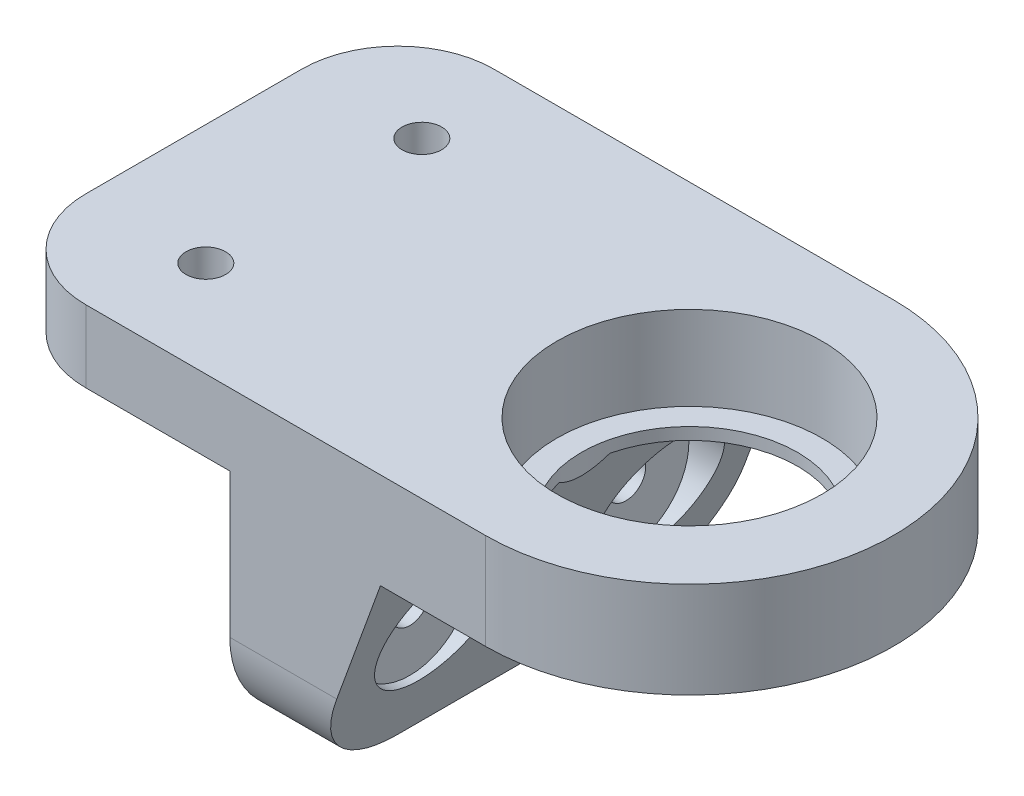
from build123d import *

# Parameters (mm, degrees)
RESSALTO_EXTRUS_O1_DEPTH   = 40
CORTE_EXTRUS_O1_DEPTH      = 66.76473219
CORTE_EXTRUS_O1_DEPTH_BACK = 66.76473219
ESBO_O2_R                  = 1.65
ESBO_O2_R_2                = 9
ESBO_O3_R                  = 1.65
CORTE_EXTRUS_O2_DEPTH      = 60.261201473
ESBO_O4_R                  = 11.05
CORTE_EXTRUS_O3_DEPTH      = 7
CORTE_EXTRUS_O5_START      = 7
ESBO_O7_R                  = 5.25
CORTE_EXTRUS_O5_DEPTH      = 10
FILETE1_R                  = 8
ESBO_O8_R                  = 5.25
CORTE_EXTRUS_O6_DEPTH      = 1
ESBO_O7_2_R                = 5.25
CORTE_EXTRUS_O7_DEPTH      = 1


with BuildPart() as part:
    # Esboço1 → Ressalto-extrusão1 (new body)
    with BuildSketch(Plane.XY):
        Polygon((0, 0), (6, 0), (12.551464217, 18), (49, 18), (49, 26), (-20, 26), (-20, 20), (0, 20), align=None)
    extrude(amount=RESSALTO_EXTRUS_O1_DEPTH)

    # Esboço2 → Corte-extrusão1 (cut, two sides: drawn at the far end of the back side and taken through both)
    with BuildSketch(Plane.XZ.offset(-18).offset(-CORTE_EXTRUS_O1_DEPTH_BACK)):
        with Locations((-10, 11)):
            Circle(ESBO_O2_R)
        with Locations((21.3, 20)):
            Circle(ESBO_O2_R_2)
        with Locations((-10, 29)):
            Circle(ESBO_O2_R)
        with BuildLine():
            Line((21.3, 3), (-20, 3))
            Line((-20, 3), (-20, 0))
            Line((-20, 0), (49, 0))
            Line((49, 0), (49, 40))
            Line((49, 40), (-20, 40))
            Line((-20, 40), (-20, 37))
            Line((-20, 37), (21.3, 37))
            ThreePointArc((21.3, 37), (38.3, 20), (21.3, 3))
        make_face()
    extrude(amount=CORTE_EXTRUS_O1_DEPTH + CORTE_EXTRUS_O1_DEPTH_BACK, mode=Mode.SUBTRACT)

    # Esboço3 → Corte-extrusão2 (cut, through all)
    with BuildSketch(Plane.ZY):
        with Locations((29, 10)):
            Circle(ESBO_O3_R)
        with Locations((11, 10)):
            Circle(ESBO_O3_R)
    extrude(amount=-CORTE_EXTRUS_O2_DEPTH, mode=Mode.SUBTRACT)

    # Esboço4 → Corte-extrusão3 (cut)
    with BuildSketch(Plane(origin=(0, 26, 0), x_dir=(1, 0, 0), z_dir=(0, 1, 0))):
        with Locations((21.3, -20)):
            Circle(ESBO_O4_R)
    extrude(amount=-CORTE_EXTRUS_O3_DEPTH, mode=Mode.SUBTRACT)

    # Esboço7 → Corte-extrusão5 (cut)
    with BuildSketch(Plane(origin=(0, 0, 0), x_dir=(0, 0, -1), z_dir=(1, 0, 0)).offset(CORTE_EXTRUS_O5_START)):
        with Locations((-29, 10)):
            Circle(ESBO_O7_R)
        with Locations((-11, 10)):
            Circle(ESBO_O7_R)
    extrude(amount=CORTE_EXTRUS_O5_DEPTH, mode=Mode.SUBTRACT)

    # Filete1
    filete1_edges = [part.edges().sort_by_distance(p)[0] for p in [
        (3, 0, 3),
        (3, 0, 37),
        (-20, 23, 37),
        (-20, 23, 3),
    ]]
    fillet(filete1_edges, radius=FILETE1_R)

    # Esboço8 → Corte-extrusão6 (cut)
    with BuildSketch(Plane.XZ.offset(-20)):
        with Locations((-10, 11)):
            Circle(ESBO_O8_R)
        with Locations((-10, 29)):
            Circle(ESBO_O8_R)
    extrude(amount=-CORTE_EXTRUS_O6_DEPTH, mode=Mode.SUBTRACT)

    # Esboço7<2> → Corte-extrusão7 (cut)
    with BuildSketch(Plane(origin=(0, 0, 0), x_dir=(0, 0, -1), z_dir=(1, 0, 0))):
        with Locations((-29, 10)):
            Circle(ESBO_O7_2_R)
        with Locations((-11, 10)):
            Circle(ESBO_O7_2_R)
    extrude(amount=CORTE_EXTRUS_O7_DEPTH, mode=Mode.SUBTRACT)


solid = part.part
